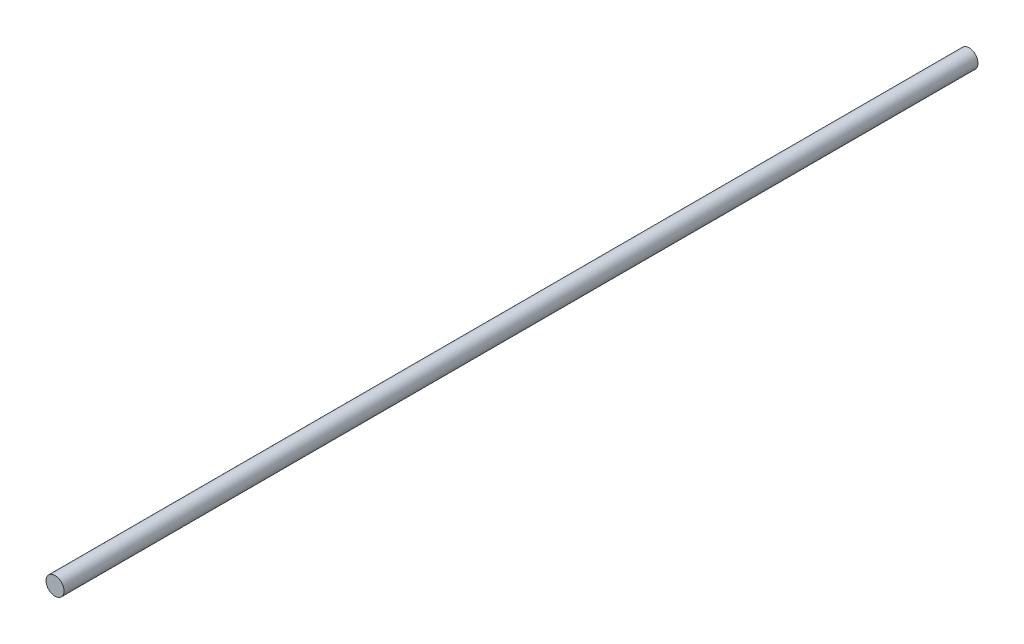
from build123d import *

# Parameters (mm, degrees)
SKETCH1_W = 4
SKETCH1_H = 406


with BuildPart() as part:
    # Sketch1 → Revolve1 (revolve)
    with BuildSketch(Plane(origin=(0, 0, 0), x_dir=(1, 0, 0), z_dir=(0, 1, 0))):
        with Locations((2, 203)):
            Rectangle(SKETCH1_W, SKETCH1_H)
    revolve(axis=Axis((0, 0, 0), (0, 0, 1)))


solid = part.part
